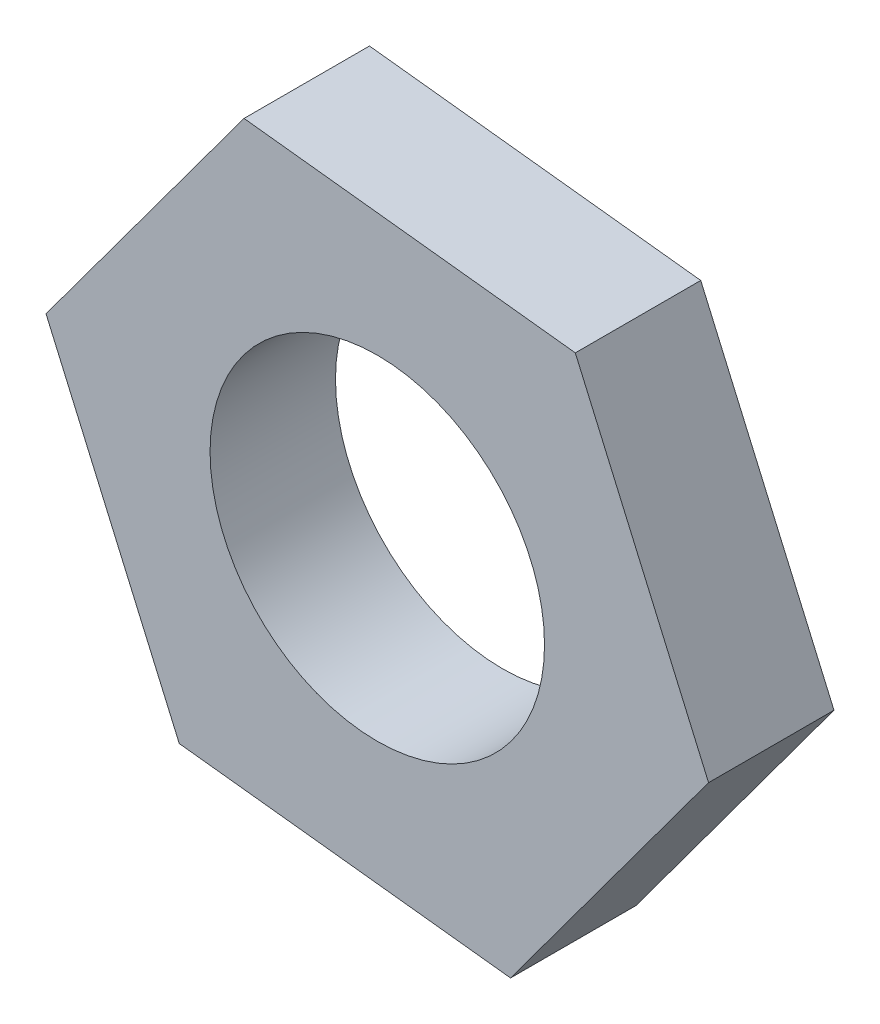
from build123d import *

# Parameters (mm, degrees)
SKETCH_1_R      = 4
EXTRUDE_2_DEPTH = 3


with BuildPart() as part:
    # 草图1 → 凸台-拉伸2 (new body)
    with BuildSketch(Plane.XY):
        Polygon((3.187153464, -7.309413891), (7.923714848, -0.894551079), (4.736561384, 6.414862811), (-3.187153464, 7.309413891), (-7.923714848, 0.894551079), (-4.736561384, -6.414862811), align=None)
        Circle(SKETCH_1_R, mode=Mode.SUBTRACT)
    extrude(amount=EXTRUDE_2_DEPTH)


solid = part.part
